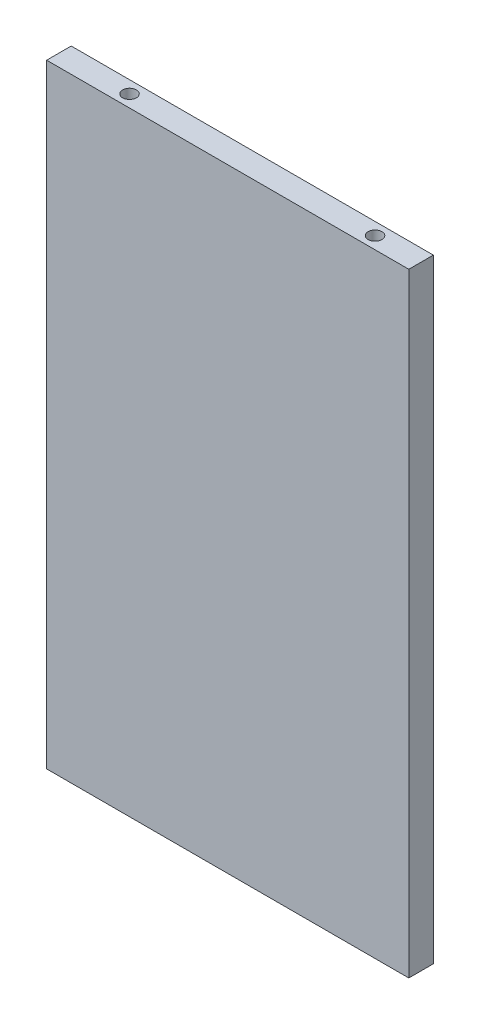
from build123d import *

# Parameters (mm, degrees)
SKETCH1_W                      = 118
SKETCH1_H                      = 8
EXTRUDE1_DEPTH                 = 200
F_4_5_4_5_DIAMETER_HOLE1_D     = 4.5
F_4_5_4_5_DIAMETER_HOLE1_DEPTH = 20
F_4_5_4_5_DIAMETER_HOLE1_TIP   = 1.351936393
F_4_5_4_5_DIAMETER_HOLE2_D     = 4.5
F_4_5_4_5_DIAMETER_HOLE2_DEPTH = 20
F_4_5_4_5_DIAMETER_HOLE2_TIP   = 1.351936393


with BuildPart() as part:
    # Sketch1 → Extrude1 (new body)
    with BuildSketch(Plane(origin=(0, 0, 0), x_dir=(1, 0, 0), z_dir=(0, 1, 0))):
        with Locations((59, 4)):
            Rectangle(SKETCH1_W, SKETCH1_H)
    extrude(amount=EXTRUDE1_DEPTH)

    # Ø4.5 (4.5) Diameter Hole1
    with Locations(Plane(origin=(23, 200, -4), x_dir=(0, 0, 1), z_dir=(0, 1, 0))):
        with Locations((0, 0), (0, 80)):
            Hole(F_4_5_4_5_DIAMETER_HOLE1_D / 2, depth=F_4_5_4_5_DIAMETER_HOLE1_DEPTH)
            with Locations((0, 0, -(F_4_5_4_5_DIAMETER_HOLE1_DEPTH + F_4_5_4_5_DIAMETER_HOLE1_TIP / 2))):  # 118° drill point
                Cone(0, F_4_5_4_5_DIAMETER_HOLE1_D / 2, F_4_5_4_5_DIAMETER_HOLE1_TIP, mode=Mode.SUBTRACT)

    # Ø4.5 (4.5) Diameter Hole2
    with Locations(Plane(origin=(23, 0, -4), x_dir=(0, 0, -1), z_dir=(0, -1, 0))):
        with Locations((0, 0), (0, 80)):
            Hole(F_4_5_4_5_DIAMETER_HOLE2_D / 2, depth=F_4_5_4_5_DIAMETER_HOLE2_DEPTH)
            with Locations((0, 0, -(F_4_5_4_5_DIAMETER_HOLE2_DEPTH + F_4_5_4_5_DIAMETER_HOLE2_TIP / 2))):  # 118° drill point
                Cone(0, F_4_5_4_5_DIAMETER_HOLE2_D / 2, F_4_5_4_5_DIAMETER_HOLE2_TIP, mode=Mode.SUBTRACT)


solid = part.part
